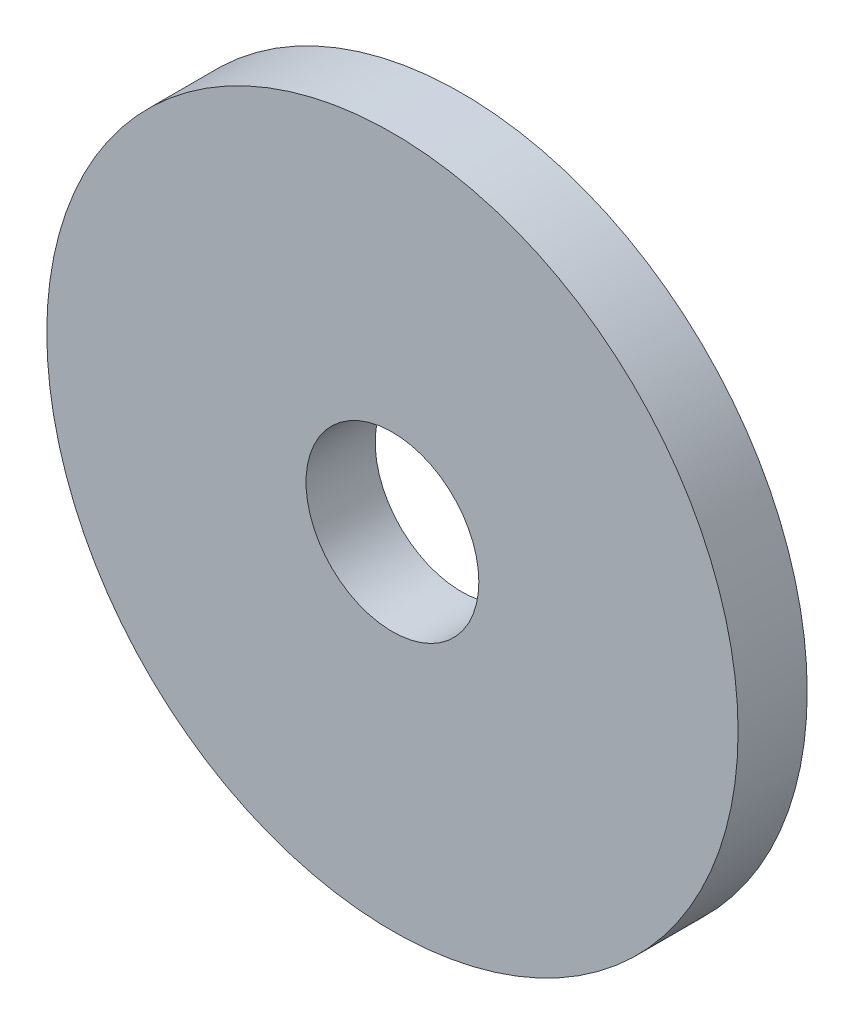
from build123d import *

# Parameters (mm, degrees)
SKETCH1_R           = 20
BOSS_EXTRUDE1_DEPTH = 4
SKETCH2_R           = 5
CUT_EXTRUDE1_DEPTH  = 4


with BuildPart() as part:
    # Sketch1 → Boss-Extrude1 (new body)
    with BuildSketch(Plane.XY):
        Circle(SKETCH1_R)
    extrude(amount=BOSS_EXTRUDE1_DEPTH)

    # Sketch2 → Cut-Extrude1 (cut)
    with BuildSketch(Plane.XY.offset(4)):
        Circle(SKETCH2_R)
    extrude(amount=-CUT_EXTRUDE1_DEPTH, mode=Mode.SUBTRACT)


solid = part.part
